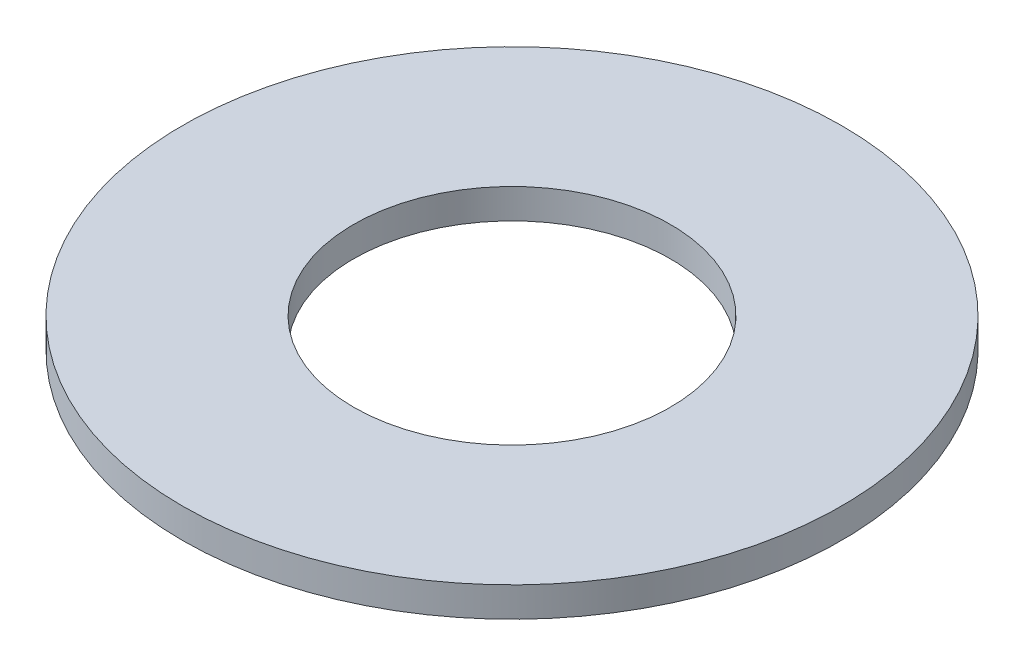
from build123d import *

# Parameters (mm, degrees)
SKETCH1_R           = 41.275
BOSS_EXTRUDE1_DEPTH = 3.7338
SKETCH5_R           = 19.8374
CUT_EXTRUDE1_DEPTH  = 4.7338


with BuildPart() as part:
    # Sketch1 → Boss-Extrude1 (new body)
    with BuildSketch(Plane(origin=(0, 0, 0), x_dir=(1, 0, 0), z_dir=(0, 1, 0))):
        Circle(SKETCH1_R)
    extrude(amount=BOSS_EXTRUDE1_DEPTH)

    # Sketch5 → Cut-Extrude1 (cut, through all)
    with BuildSketch(Plane(origin=(0, 3.7338, 0), x_dir=(-1, 0, 0), z_dir=(0, 1, 0))):
        Circle(SKETCH5_R)
    extrude(amount=-CUT_EXTRUDE1_DEPTH, mode=Mode.SUBTRACT)


solid = part.part
